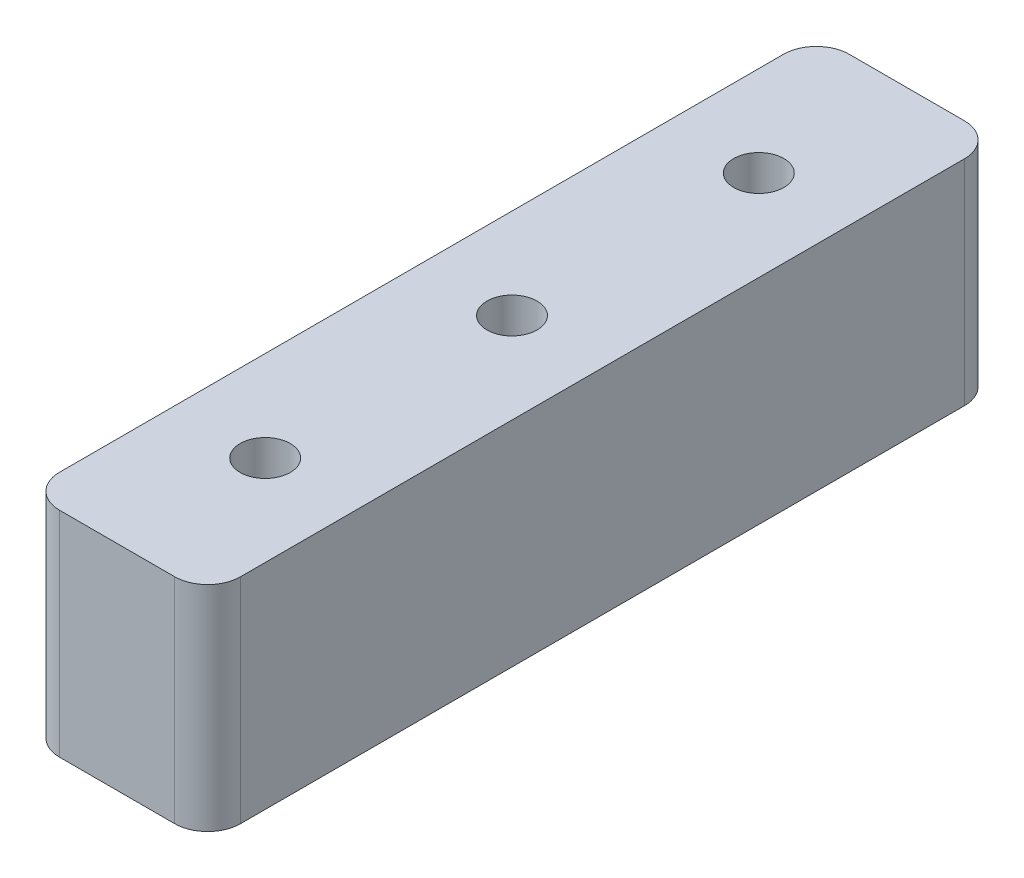
from build123d import *

# Parameters (mm, degrees)
SKETCH_1_W          = 11
SKETCH_1_H          = 48
EXTRUDE_1_DEPTH     = 13
FILLET_1_R          = 2
SKETCH_5_R          = 1.525
CUT_EXTRUDE_1_DEPTH = 14


with BuildPart() as part:
    # 草图1 → 凸台-拉伸1 (new body)
    with BuildSketch(Plane(origin=(0, 0, 0), x_dir=(1, 0, 0), z_dir=(0, 1, 0))):
        Rectangle(SKETCH_1_W, SKETCH_1_H)
    extrude(amount=EXTRUDE_1_DEPTH)

    # 圆角1
    fillet_1_edges = [part.edges().sort_by_distance(p)[0] for p in [
        (5.5, 6.5, 24),
        (-5.5, 6.5, 24),
        (-5.5, 6.5, -24),
        (5.5, 6.5, -24),
    ]]
    fillet(fillet_1_edges, radius=FILLET_1_R)

    # 草图5 → 切除-拉伸1 (cut, through all)
    with BuildSketch(Plane(origin=(0, 13, 0), x_dir=(1, 0, 0), z_dir=(0, 1, 0))):
        Circle(SKETCH_5_R)
        with Locations((0, 15)):
            Circle(SKETCH_5_R)
        with Locations((0, -15)):
            Circle(SKETCH_5_R)
    extrude(amount=-CUT_EXTRUDE_1_DEPTH, mode=Mode.SUBTRACT)


solid = part.part
